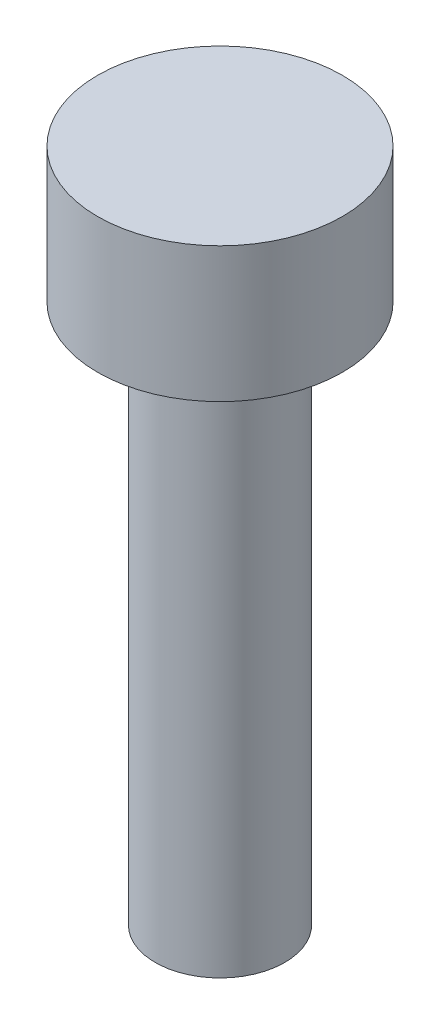
from build123d import *

# Parameters (mm, degrees)
SKETCH1_R           = 2.72
BOSS_EXTRUDE1_DEPTH = 3
SKETCH2_R           = 1.44
BOSS_EXTRUDE2_DEPTH = 12


with BuildPart() as part:
    # Sketch1 → Boss-Extrude1 (new body)
    with BuildSketch(Plane(origin=(0, 0, 0), x_dir=(1, 0, 0), z_dir=(0, 1, 0))):
        Circle(SKETCH1_R)
    extrude(amount=BOSS_EXTRUDE1_DEPTH)

    # Sketch2 → Boss-Extrude2 (add)
    with BuildSketch(Plane.XZ):
        Circle(SKETCH2_R)
    extrude(amount=BOSS_EXTRUDE2_DEPTH)


solid = part.part
